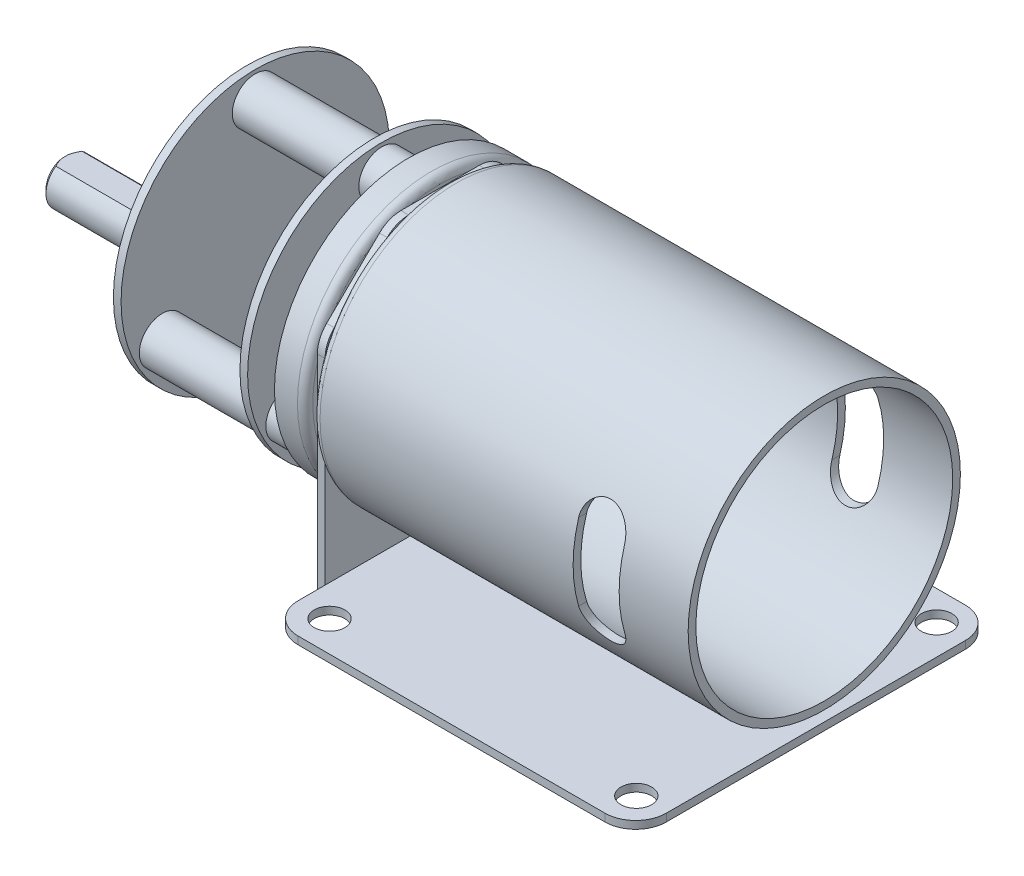
from build123d import *

# Parameters (mm, degrees)
SKETCH1_R               = 2
EXTRUDE1_DEPTH          = 1
SKETCH2_W               = 1
SKETCH2_H               = 32
EXTRUDE2_DEPTH          = 38
SKETCH3_R               = 12.5
EXTRUDE3_DEPTH          = 0.1
EXTRUDE3_DEPTH_BACK     = 1.1
SKETCH4_R               = 17.75
EXTRUDE4_DEPTH          = 1
SKETCH5_R               = 17.75
SKETCH5_R_2             = 16.75
EXTRUDE5_DEPTH          = 48
CUT_EXTRUDE1_DEPTH      = 48
CUT_EXTRUDE1_DEPTH_BACK = 48
SKETCH7_R               = 17.5
EXTRUDE6_DEPTH          = 4
SKETCH8_R               = 3
EXTRUDE7_DEPTH          = 21
SKETCH9_R               = 17.5
EXTRUDE8_DEPTH          = 1
FILLET1_R               = 1
SKETCH10_R              = 6
EXTRUDE9_DEPTH          = 8.8
SKETCH12_R              = 2.99
EXTRUDE10_DEPTH         = 15
CHAMFER1_SIZE           = 0.5
SKETCH13_W              = 8.822132464
SKETCH13_H              = 3.665499941
CUT_EXTRUDE2_DEPTH      = 12
SKETCH14_R              = 17.5
EXTRUDE11_DEPTH         = 1
CUT_EXTRUDE3_DEPTH      = 1


with BuildPart() as part:
    # Sketch1 → Extrude1 (new body)
    with BuildSketch(Plane(origin=(0, 0, 0), x_dir=(1, 0, 0), z_dir=(0, 1, 0))):
        with BuildLine():
            Line((-20, 23.5), (20, 23.5))
            ThreePointArc((20, 23.5), (22.828427125, 22.328427125), (24, 19.5))
            Line((24, 19.5), (24, -19.5))
            ThreePointArc((24, -19.5), (22.828427125, -22.328427125), (20, -23.5))
            Line((20, -23.5), (-20, -23.5))
            ThreePointArc((-20, -23.5), (-22.828427125, -22.328427125), (-24, -19.5))
            Line((-24, -19.5), (-24, 19.5))
            ThreePointArc((-24, 19.5), (-22.828427125, 22.328427125), (-20, 23.5))
        make_face()
        with Locations(Location((-19.914893617, 19.5, 0), (0, 0, 270))):  # turned: the seam where the file's is
            Circle(SKETCH1_R, mode=Mode.SUBTRACT)
        with Locations(Location((20.085106383, 19.666666667, 0), (0, 0, 270))):  # turned: the seam where the file's is
            Circle(SKETCH1_R, mode=Mode.SUBTRACT)
        with Locations(Location((-19.914893617, -19.5, 0), (0, 0, 270))):  # turned: the seam where the file's is
            Circle(SKETCH1_R, mode=Mode.SUBTRACT)
        with Locations(Location((20.085106383, -19.5, 0), (0, 0, 270))):  # turned: the seam where the file's is
            Circle(SKETCH1_R, mode=Mode.SUBTRACT)
    extrude(amount=EXTRUDE1_DEPTH)

    # Sketch2 → Extrude2 (add)
    with BuildSketch(Plane.XZ):
        with Locations((-24.5, 0)):
            Rectangle(SKETCH2_W, SKETCH2_H)
    extrude(amount=-EXTRUDE2_DEPTH)

    # Sketch3 → Extrude3 (add, two sides)
    with BuildSketch(Plane(origin=(-24, 0, 0), x_dir=(0, 0, -1), z_dir=(1, 0, 0))) as extrude3_sk:
        with Locations((0, 21.2)):
            Circle(SKETCH3_R)
    extrude(amount=EXTRUDE3_DEPTH)
    extrude(extrude3_sk.sketch, amount=-EXTRUDE3_DEPTH_BACK)

    # Sketch4 → Extrude4 (add)
    with BuildSketch(Plane(origin=(-23.9, 0, 0), x_dir=(0, 0, -1), z_dir=(1, 0, 0))):
        with Locations((0, 21.2)):
            Circle(SKETCH4_R)
    extrude(amount=EXTRUDE4_DEPTH)

    # Sketch5 → Extrude5 (add)
    with BuildSketch(Plane(origin=(-22.9, 0, 0), x_dir=(0, 0, -1), z_dir=(1, 0, 0))):
        with Locations((0, 21.2)):
            Circle(SKETCH5_R)
        with Locations((0, 21.2)):
            Circle(SKETCH5_R_2, mode=Mode.SUBTRACT)
    extrude(amount=EXTRUDE5_DEPTH)

    # Sketch6 → Cut-Extrude1 (cut, two sides)
    with BuildSketch(Plane.XY) as cut_extrude1_sk:
        with BuildLine():
            Line((10.1, 26.2), (10.1, 16.2))
            ThreePointArc((10.1, 16.2), (13.1, 13.2), (16.1, 16.2))
            Line((16.1, 16.2), (16.1, 26.2))
            ThreePointArc((16.1, 26.2), (13.1, 29.2), (10.1, 26.2))
        make_face()
    extrude(amount=CUT_EXTRUDE1_DEPTH, mode=Mode.SUBTRACT)
    extrude(cut_extrude1_sk.sketch, amount=-CUT_EXTRUDE1_DEPTH_BACK, mode=Mode.SUBTRACT)

    # Sketch7 → Extrude6 (add)
    with BuildSketch(Plane.ZY.offset(25.1)):
        with Locations((0, 21.2)):
            Circle(SKETCH7_R)
    extrude(amount=EXTRUDE6_DEPTH)

    # Sketch8 → Extrude7 (add)
    with BuildSketch(Plane.ZY.offset(29.1)):
        with Locations((0, 35.2)):
            Circle(SKETCH8_R)
        with Locations((12.124355653, 14.2)):
            Circle(SKETCH8_R)
        with Locations((-12.124355653, 14.2)):
            Circle(SKETCH8_R)
    extrude(amount=EXTRUDE7_DEPTH)

    # Sketch9 → Extrude8 (add)
    with BuildSketch(Plane.ZY.offset(50.1)):
        with Locations((0, 21.2)):
            Circle(SKETCH9_R)
    extrude(amount=-EXTRUDE8_DEPTH)

    # Fillet1
    fillet1_edges = [part.edges().sort_by_distance(p)[0] for p in [
        (-25.1, 21.2, -17.5),
        (-23.9, 21.2, 17.75),
        (-22.9, 21.2, 16.75),
    ]]
    fillet(fillet1_edges, radius=FILLET1_R)

    # Sketch10 → Extrude9 (add)
    with BuildSketch(Plane.ZY.offset(50.1)):
        with Locations(Location((0, 14, 0), (0, 0, 180))):  # turned: the seam where the file's is
            Circle(SKETCH10_R)
    extrude(amount=EXTRUDE9_DEPTH)

    # Sketch12 → Extrude10 (add)
    with BuildSketch(Plane.ZY.offset(58.9)):
        with Locations(Location((0, 14, 0), (0, 0, 180))):  # turned: the seam where the file's is
            Circle(SKETCH12_R)
    extrude(amount=EXTRUDE10_DEPTH)

    # Chamfer1
    chamfer1_edges = [part.edges().sort_by_distance(p)[0] for p in [
        (-58.9, 14, 6),
        (-73.9, 14, 2.99),
    ]]
    chamfer(chamfer1_edges, length=CHAMFER1_SIZE)

    # Sketch13 → Cut-Extrude2 (cut)
    with BuildSketch(Plane.ZY.offset(73.9)):
        with Locations((0.15693732, 18.292749971)):
            Rectangle(SKETCH13_W, SKETCH13_H)
    extrude(amount=-CUT_EXTRUDE2_DEPTH, mode=Mode.SUBTRACT)

    # Sketch14 → Extrude11 (add)
    with BuildSketch(Plane.ZY.offset(32.6)):
        with Locations((0, 21.2)):
            Circle(SKETCH14_R)
    extrude(amount=EXTRUDE11_DEPTH)

    # Sketch15 → Cut-Extrude3 (cut)
    with BuildSketch(Plane.ZY.offset(25)):
        with BuildLine():
            Line((-33.874184882, 26.312654404), (-16, 20.119575519))
            Line((-16, 20.119575519), (-16, 26.605908372))
            ThreePointArc((-16, 26.605908372), (-15.687001368, 28.157043736), (-14.796989542, 29.465427475))
            Line((-14.796989542, 29.465427475), (-7.899269666, 36.212313809))
            ThreePointArc((-7.899269666, 36.212313809), (-6.612565459, 37.056716709), (-5.102280124, 37.352794705))
            Line((-5.102280124, 37.352794705), (5.102280124, 37.352794705))
            ThreePointArc((5.102280124, 37.352794705), (6.612565459, 37.056716709), (7.899269666, 36.212313809))
            Line((7.899269666, 36.212313809), (14.796989542, 29.465427475))
            ThreePointArc((14.796989542, 29.465427475), (15.687001368, 28.157043736), (16, 26.605908372))
            Line((16, 26.605908372), (16, 20.119575519))
            Line((16, 20.119575519), (28.647949719, 26.312654404))
            Line((28.647949719, 26.312654404), (28.647949719, 45.536112941))
            Line((28.647949719, 45.536112941), (-33.874184882, 45.536112941))
            Line((-33.874184882, 45.536112941), (-33.874184882, 26.312654404))
        make_face()
    extrude(amount=-CUT_EXTRUDE3_DEPTH, mode=Mode.SUBTRACT)


solid = part.part
